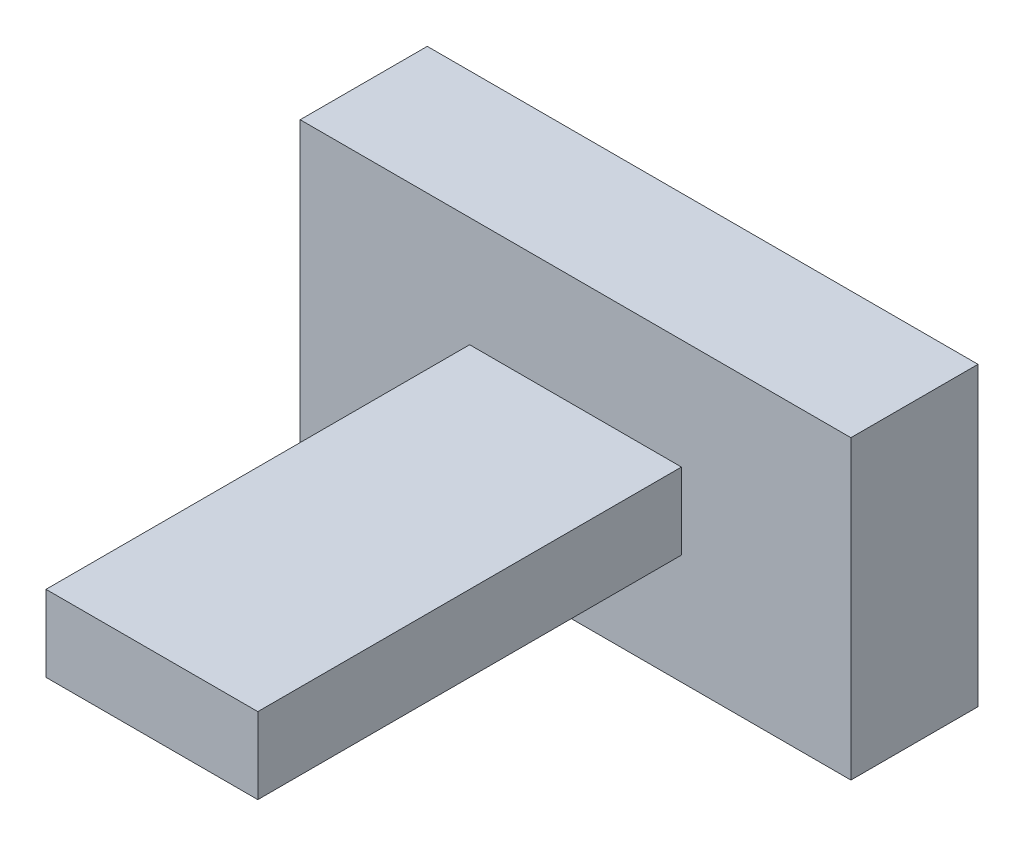
from build123d import *

# Parameters (mm, degrees)
ESQUISSE2_W        = 13
ESQUISSE2_H        = 7
BOSS_EXTRU_1_DEPTH = 3
ESQUISSE4_W        = 5
ESQUISSE4_H        = 1.8
BOSS_EXTRU_2_DEPTH = 10


with BuildPart() as part:
    # Esquisse2 → Boss.-Extru.1 (new body)
    with BuildSketch(Plane.XY):
        with Locations((6.5, 3.5)):
            Rectangle(ESQUISSE2_W, ESQUISSE2_H)
    extrude(amount=BOSS_EXTRU_1_DEPTH)

    # Esquisse4 → Boss.-Extru.2 (add)
    with BuildSketch(Plane.XY.offset(3)):
        with Locations((6.5, 3.5)):
            Rectangle(ESQUISSE4_W, ESQUISSE4_H)
    extrude(amount=BOSS_EXTRU_2_DEPTH)


solid = part.part
